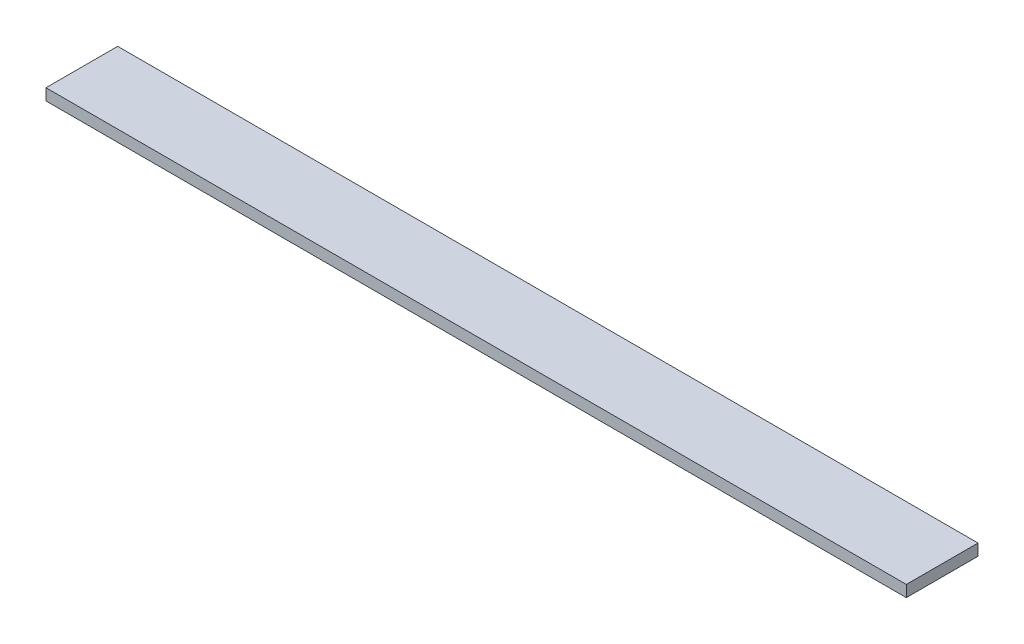
from build123d import *

# Parameters (mm, degrees)
SKETCH_1_W      = 600
SKETCH_1_H      = 50
EXTRUDE_1_DEPTH = 8


with BuildPart() as part:
    # Эскиз1 → Бобышка-Вытянуть1 (new body)
    with BuildSketch(Plane(origin=(0, 0, 0), x_dir=(1, 0, 0), z_dir=(0, 1, 0))):
        Rectangle(SKETCH_1_W, SKETCH_1_H)
    extrude(amount=EXTRUDE_1_DEPTH)


solid = part.part
